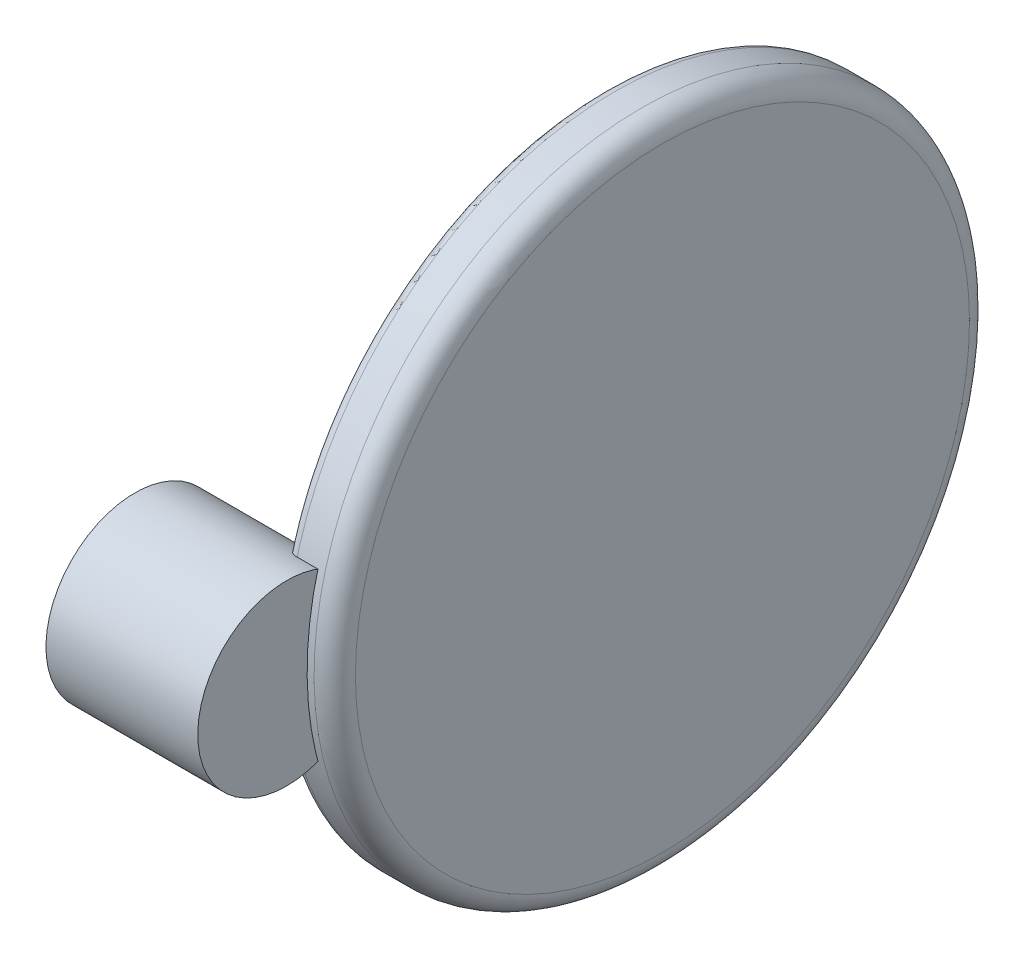
from build123d import *

# Parameters (mm, degrees)
SKETCH1_W          = 22
SKETCH1_H          = 12.9
SKETCH2_R          = 3.71375
CUT_EXTRUDE1_DEPTH = 7.5725
SKETCH5_W          = 8.5
SKETCH5_H          = 47.5
FILLET1_R          = 3
FILLET2_R          = 1.5


with BuildPart() as part:
    # Sketch1 → Revolve1 (revolve)
    with BuildSketch(Plane.XY):
        with Locations((19.255, 6.45)):
            Rectangle(SKETCH1_W, SKETCH1_H)
    revolve(axis=Axis((8.255, 0, 0), (1, 0, 0)))

    # Sketch2 → Cut-Extrude1 (cut)
    with BuildSketch(Plane.ZY.offset(-8.255)):
        Circle(SKETCH2_R)
    extrude(amount=-CUT_EXTRUDE1_DEPTH, mode=Mode.SUBTRACT)


with BuildPart() as body_2:
    # Body-Move/Copy1: copy of part
    add(part.part.moved(Location((0, 0, 50.452769062))))


with BuildPart() as part_1:
    add(part.part)

    # Sketch5 → Revolve2 (revolve)
    with BuildSketch(Plane.XY):
        with Locations((30.005, 23.75)):
            Rectangle(SKETCH5_W, SKETCH5_H)
    revolve(axis=Axis((34.255, 0, 0), (-1, 0, 0)))

    # Fillet1
    fillet1_edges = [part_1.edges().sort_by_distance(p)[0] for p in [
        (34.255, -47.5, 0),
    ]]
    fillet(fillet1_edges, radius=FILLET1_R)

    # Fillet2
    fillet2_edges = [part_1.edges().sort_by_distance(p)[0] for p in [
        (25.755, -47.5, 0),
    ]]
    fillet(fillet2_edges, radius=FILLET2_R)


solid = Compound([body_2.part, part_1.part])
